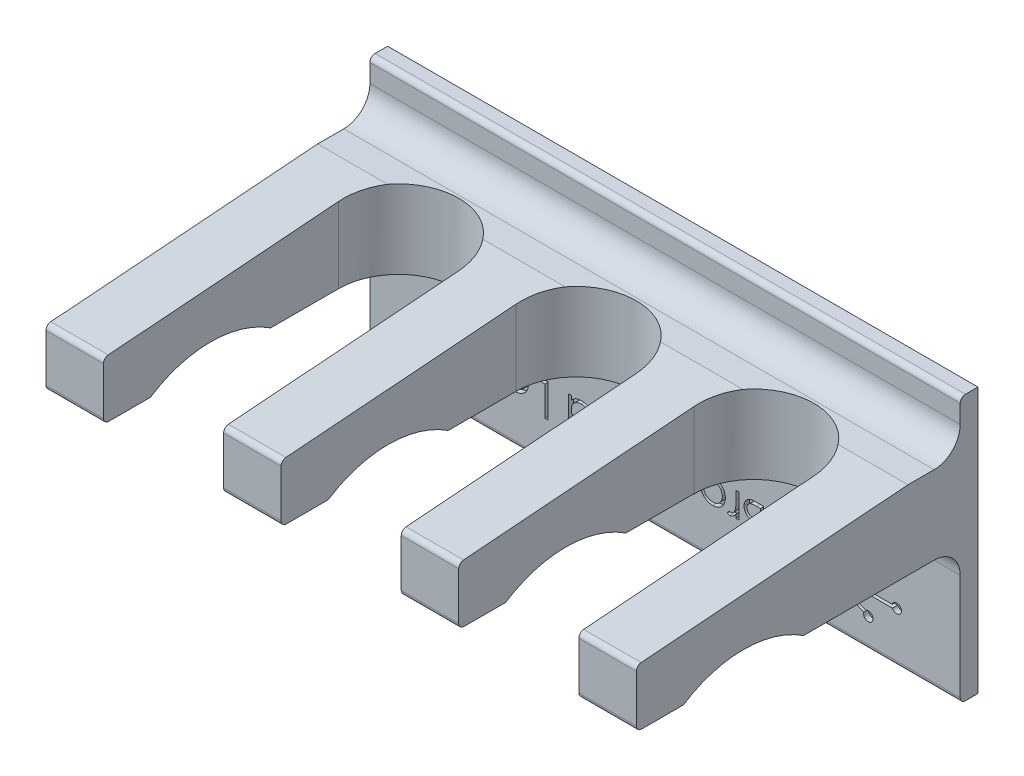
from build123d import *

# Parameters (mm, degrees)
SKETCH1_W                = 113
SKETCH1_H                = 3.4
BOSS_EXTRUDE1_DEPTH      = 30
BOSS_EXTRUDE1_DEPTH_BACK = 20.8
SKETCH2_W                = 113
SKETCH2_H                = 15
BOSS_EXTRUDE2_DEPTH      = 62
CUT_EXTRUDE1_DEPTH       = 1
CUT_EXTRUDE1_DEPTH_BACK  = 114
SKETCH5_W                = 23
SKETCH5_H                = 13
SKETCH5_H_2              = 32
CUT_EXTRUDE5_DEPTH       = 25.5
CUT_EXTRUDE5_DEPTH_BACK  = 27.3
FILLET1_R                = 5
FILLET2_R                = 1
FILLET3_R                = 1
CUT_EXTRUDE6_DEPTH       = 1
CUT_EXTRUDE7_DEPTH       = 1


with BuildPart() as part:
    # Sketch1 → Boss-Extrude1 (new body, two sides)
    with BuildSketch(Plane(origin=(0, 0, 0), x_dir=(1, 0, 0), z_dir=(0, 1, 0))) as boss_extrude1_sk:
        Rectangle(SKETCH1_W, SKETCH1_H)
    extrude(amount=BOSS_EXTRUDE1_DEPTH)
    extrude(boss_extrude1_sk.sketch, amount=-BOSS_EXTRUDE1_DEPTH_BACK)

    # Sketch2 → Boss-Extrude2 (add)
    with BuildSketch(Plane.XY.offset(1.7)):
        with Locations((0, 13)):
            Rectangle(SKETCH2_W, SKETCH2_H)
    extrude(amount=BOSS_EXTRUDE2_DEPTH)

    # Sketch4 → Cut-Extrude1 (cut, two sides)
    with BuildSketch(Plane.ZY.offset(56.5)) as cut_extrude1_sk:
        with BuildLine():
            Line((31.7, 5.5), (54.7, 5.5))
            ThreePointArc((54.7, 5.5), (43.2, 8.9278273), (31.7, 5.5))
        make_face()
        Polygon((63.7, 20.5), (11.7, 20.5), (63.7, 16.5), align=None)
    extrude(amount=CUT_EXTRUDE1_DEPTH, mode=Mode.SUBTRACT)
    extrude(cut_extrude1_sk.sketch, amount=-CUT_EXTRUDE1_DEPTH_BACK, mode=Mode.SUBTRACT)

    # Sketch5 → Cut-Extrude5 (cut, two sides)
    with BuildSketch(Plane(origin=(0, 5.5, 1.030668591), x_dir=(1, 0, 0), z_dir=(0, 1, 0))) as cut_extrude5_sk:
        with Locations((34, -24.169331409)):
            Rectangle(SKETCH5_W, SKETCH5_H)
        with Locations((34, -46.669331409)):
            Rectangle(SKETCH5_W, SKETCH5_H_2)
        with BuildLine():
            Line((22.5, -17.669331409), (45.5, -17.669331409))
            ThreePointArc((45.5, -17.669331409), (34, -6.169331409), (22.5, -17.669331409))
        make_face()
        with BuildLine():
            Line((-11.5, -17.669331409), (11.5, -17.669331409))
            ThreePointArc((11.5, -17.669331409), (0, -6.169331409), (-11.5, -17.669331409))
        make_face()
        with Locations((0, -24.169331409)):
            Rectangle(SKETCH5_W, SKETCH5_H)
        with Locations((0, -46.669331409)):
            Rectangle(SKETCH5_W, SKETCH5_H_2)
        with Locations((-34, -24.169331409)):
            Rectangle(SKETCH5_W, SKETCH5_H)
        with Locations((-34, -46.669331409)):
            Rectangle(SKETCH5_W, SKETCH5_H_2)
        with BuildLine():
            Line((-45.5, -17.669331409), (-22.5, -17.669331409))
            ThreePointArc((-22.5, -17.669331409), (-34, -6.169331409), (-45.5, -17.669331409))
        make_face()
    extrude(amount=CUT_EXTRUDE5_DEPTH, mode=Mode.SUBTRACT)
    extrude(cut_extrude5_sk.sketch, amount=-CUT_EXTRUDE5_DEPTH_BACK, mode=Mode.SUBTRACT)

    # Fillet1
    fillet1_edges = [part.edges().sort_by_distance(p)[0] for p in [
        (0, 20.5, 1.7),
        (0, 5.5, 1.7),
    ]]
    fillet(fillet1_edges, radius=FILLET1_R)

    # Fillet2
    fillet2_edges = [part.edges().sort_by_distance(p)[0] for p in [
        (0, -20.8, 1.7),
        (0, 30, 1.7),
    ]]
    fillet(fillet2_edges, radius=FILLET2_R)

    # Fillet3
    fillet3_edges = [part.edges().sort_by_distance(p)[0] for p in [
        (-51, 5.5, 63.7),
        (51, 5.5, 63.7),
        (-51, 16.5, 63.7),
        (51, 16.5, 63.7),
        (-17, 5.5, 63.7),
        (-17, 16.5, 63.7),
        (17, 5.5, 63.7),
        (17, 16.5, 63.7),
    ]]
    fillet(fillet3_edges, radius=FILLET3_R)

    # Sketch6 → Cut-Extrude6 (cut)
    with BuildSketch(Plane.XY.offset(1.7)):
        with BuildLine():
            ThreePointArc((30.34513405, -13.148436359), (32.587188023, -10.934389264), (30.34513405, -8.720342169))
            Line((30.34513405, -8.720342169), (30.34513405, -13.148436359))
        make_face()
        with BuildLine():
            ThreePointArc((32.387441567, -11.853447127), (32.24184238, -12.12185726), (32.060700113, -12.367683626))
            Line((32.060700113, -12.367683626), (38.039510272, -14.835483008))
            ThreePointArc((38.039510272, -14.835483008), (39.610179565, -15.655987061), (38.41974035, -14.343324346))
            Line((38.41974035, -14.343324346), (32.387441567, -11.853447127))
        make_face()
        with BuildLine():
            Line((43.46867274, -10.840081745), (32.585178752, -10.840081745))
            ThreePointArc((32.585178752, -10.840081745), (32.577432245, -11.142013304), (32.528668735, -11.440081745))
            Line((32.528668735, -11.440081745), (43.52283179, -11.440081745))
            ThreePointArc((43.52283179, -11.440081745), (45.236769861, -10.982928647), (43.46867274, -10.840081745))
        make_face()
        with BuildLine():
            Line((40.600693883, -5.29166271), (32.008087594, -9.441353251))
            ThreePointArc((32.008087594, -9.441353251), (32.197318076, -9.679591006), (32.352104444, -9.941519591))
            Line((32.352104444, -9.941519591), (40.937031121, -5.795537821))
            ThreePointArc((40.937031121, -5.795537821), (42.222305686, -4.573425208), (40.600693883, -5.29166271))
        make_face()
        with BuildLine():
            Line((34.263370153, -3.898677216), (31.204024561, -8.882044062))
            ThreePointArc((31.204024561, -8.882044062), (31.474546268, -9.013634185), (31.724734456, -9.180678568))
            Line((31.724734456, -9.180678568), (34.768542833, -4.222620286))
            ThreePointArc((34.768542833, -4.222620286), (35.459803154, -2.588768066), (34.263370153, -3.898677216))
        make_face()
    extrude(amount=-CUT_EXTRUDE6_DEPTH, mode=Mode.SUBTRACT)

    # Sketch8 → Cut-Extrude7 (cut)
    with BuildSketch(Plane.XY.offset(1.7)):
        with BuildLine():
            Line((18.858305169, -13.246753353), (17.61934283, -13.246753353))
            add(Edge.make_bspline(
                [(17.61934283, -13.246753353), (17.558693063, -13.246439511), (17.44113872, -13.245831208), (17.270210732, -13.236177878), (17.110057146, -13.223344689), (16.960960974, -13.201817705), (16.82195207, -13.179497061), (16.694441666, -13.146735701), (16.577361703, -13.110549584), (16.436772632, -13.054872333), (16.277255068, -12.968404859), (16.105803534, -12.84016538), (15.956767399, -12.6864166), (15.830042508, -12.511207737), (15.728343086, -12.318458134), (15.655698842, -12.11231486), (15.609029413, -11.896246028), (15.60429009, -11.748110867), (15.601894913, -11.673245741)],
                knots=[0, 0, 0, 0, 0.000181919, 0.000352604, 0.00051349, 0.000663703, 0.000804446, 0.000935564, 0.001058268, 0.001171886, 0.001388733, 0.0016004, 0.001811791, 0.002028575, 0.002247069, 0.002463125, 0.00268266, 0.002906975, 0.002906975, 0.002906975, 0.002906975], degree=3))
            add(Edge.make_bspline(
                [(15.601894913, -11.673245741), (15.603851328, -11.603110006), (15.607695867, -11.465286672), (15.645253907, -11.264379878), (15.701946858, -11.0725319), (15.783758229, -10.891591568), (15.888074602, -10.723148801), (16.014991144, -10.570076804), (16.165479379, -10.43538088), (16.278466777, -10.360420682), (16.335859256, -10.322344299)],
                knots=[0, 0, 0, 0, 0.000210198, 0.000413059, 0.000611047, 0.000809174, 0.001006844, 0.001203751, 0.001403723, 0.001610162, 0.001610162, 0.001610162, 0.001610162], degree=3))
            add(Edge.make_bspline(
                [(16.335859256, -10.322344299), (16.263717361, -10.294661646), (16.125692044, -10.241697875), (15.935505587, -10.147695874), (15.771591767, -10.046237996), (15.631838185, -9.936580585), (15.514734558, -9.815143016), (15.410413944, -9.68512343), (15.321880246, -9.541993685), (15.246341249, -9.388855335), (15.18650236, -9.226519343), (15.144965851, -9.056200176), (15.118623264, -8.879826934), (15.115178491, -8.759954482), (15.113433375, -8.699227311)],
                knots=[0, 0, 0, 0, 0.000231723, 0.000443344, 0.00063535, 0.000809177, 0.000974689, 0.001140371, 0.001308376, 0.001478472, 0.001651922, 0.001826233, 0.002003608, 0.002185726, 0.002185726, 0.002185726, 0.002185726], degree=3))
            add(Edge.make_bspline(
                [(15.113433375, -8.699227311), (15.115205822, -8.637238946), (15.118693163, -8.515275102), (15.144417254, -8.336103599), (15.187985563, -8.164885895), (15.247953218, -8.000482291), (15.326124074, -7.843855652), (15.420562593, -7.693775065), (15.533908733, -7.552464748), (15.661547636, -7.417874113), (15.803955929, -7.294796792), (15.960878726, -7.18902819), (16.128294259, -7.0976715), (16.308495084, -7.024225845), (16.500202552, -6.966731331), (16.703461575, -6.926979719), (16.918156734, -6.900087504), (17.065496564, -6.897883595), (17.141057573, -6.896753353)],
                knots=[0, 0, 0, 0, 0.00018593, 0.000365823, 0.000541677, 0.000715127, 0.000889772, 0.001065869, 0.001246054, 0.001432298, 0.001621733, 0.00180943, 0.001998968, 0.002192906, 0.002392113, 0.002598422, 0.002813633, 0.003040184, 0.003040184, 0.003040184, 0.003040184], degree=3))
            Line((17.141057573, -6.896753353), (18.858305169, -6.896753353))
            Line((18.858305169, -6.896753353), (18.858305169, -13.246753353))
        make_face()
        with BuildLine():
            Line((18.288433375, -12.595471302), (18.288433375, -10.560214891))
            Line((18.288433375, -10.560214891), (17.905550762, -10.560214891))
            add(Edge.make_bspline(
                [(17.905550762, -10.560214891), (17.84958173, -10.560934428), (17.741438152, -10.562324719), (17.584413011, -10.566432769), (17.439021013, -10.577431758), (17.304761194, -10.589065024), (17.182533319, -10.606977798), (17.07192854, -10.628898233), (16.971952184, -10.651877703), (16.856713321, -10.69107077), (16.726012691, -10.748387691), (16.587657647, -10.83951708), (16.463131889, -10.945025211), (16.360405325, -11.070174341), (16.274881733, -11.205324084), (16.217302019, -11.351482255), (16.177155301, -11.503612204), (16.173581305, -11.608528885), (16.171766708, -11.661797424)],
                knots=[0, 0, 0, 0, 0.000167928, 0.000324471, 0.000471109, 0.000605277, 0.000728684, 0.000841444, 0.000943564, 0.001036082, 0.001206311, 0.001370024, 0.001531452, 0.001693994, 0.001853912, 0.002009105, 0.002163672, 0.002323088, 0.002323088, 0.002323088, 0.002323088], degree=3))
            add(Edge.make_bspline(
                [(16.171766708, -11.661797424), (16.172651716, -11.697062359), (16.174387757, -11.76623838), (16.190754098, -11.867023871), (16.213339453, -11.962931827), (16.250588329, -12.051376742), (16.294718621, -12.135464276), (16.351283113, -12.212538267), (16.416507176, -12.284686656), (16.49255026, -12.349975575), (16.579101514, -12.409025633), (16.678902679, -12.458181987), (16.789240404, -12.501866639), (16.912415576, -12.534980629), (17.045974657, -12.563728844), (17.191955283, -12.581857308), (17.349477678, -12.59350332), (17.458618938, -12.594800676), (17.515035939, -12.595471302)],
                knots=[0, 0, 0, 0, 0.000105701, 0.000207345, 0.000305761, 0.000400483, 0.00049439, 0.000590064, 0.000686411, 0.000785614, 0.000890045, 0.000999838, 0.001118656, 0.00124551, 0.001381974, 0.001528235, 0.001686383, 0.001855606, 0.001855606, 0.001855606, 0.001855606], degree=3))
            Line((17.515035939, -12.595471302), (18.288433375, -12.595471302))
        make_face(mode=Mode.SUBTRACT)
        with BuildLine():
            Line((18.288433375, -9.90893284), (18.288433375, -7.548035404))
            Line((18.288433375, -7.548035404), (17.476874881, -7.548035404))
            add(Edge.make_bspline(
                [(17.476874881, -7.548035404), (17.418789208, -7.548798579), (17.306836732, -7.550269498), (17.145073619, -7.553759786), (16.995940409, -7.566708741), (16.858195413, -7.5791234), (16.732475964, -7.599405324), (16.617559224, -7.619045225), (16.516069946, -7.647946309), (16.397321628, -7.687714713), (16.264502829, -7.751269893), (16.119458434, -7.84473323), (15.991704493, -7.958578461), (15.883314226, -8.089664782), (15.793192471, -8.230724634), (15.730846014, -8.382035647), (15.69044906, -8.538543787), (15.68569126, -8.645558312), (15.683305169, -8.699227311)],
                knots=[0, 0, 0, 0, 0.000174287, 0.000335916, 0.000485184, 0.000623274, 0.000750643, 0.000867151, 0.000972691, 0.001066822, 0.001242648, 0.001412707, 0.001582993, 0.001753678, 0.001921683, 0.002083036, 0.002242848, 0.002403628, 0.002403628, 0.002403628, 0.002403628], degree=3))
            add(Edge.make_bspline(
                [(15.683305169, -8.699227311), (15.683792244, -8.732784547), (15.684758536, -8.799357738), (15.699947684, -8.89710307), (15.721026338, -8.992255374), (15.752090352, -9.083522167), (15.789669363, -9.172475047), (15.839245652, -9.25621965), (15.89516734, -9.338320853), (15.981781576, -9.443337381), (16.109480678, -9.56287359), (16.291009458, -9.678444576), (16.496259942, -9.7731586), (16.645476537, -9.81319895), (16.722557974, -9.83388276)],
                knots=[0, 0, 0, 0, 0.000100563, 0.000199504, 0.000296087, 0.000392628, 0.000488335, 0.00058521, 0.000684004, 0.000786124, 0.000993126, 0.001205526, 0.001429234, 0.001668282, 0.001668282, 0.001668282, 0.001668282], degree=3))
            add(Edge.make_bspline(
                [(16.722557974, -9.83388276), (16.75345359, -9.840151691), (16.82044166, -9.853744026), (16.929675968, -9.868082757), (17.054800637, -9.880945065), (17.195280863, -9.89020952), (17.351675354, -9.900154751), (17.523933866, -9.903884819), (17.712178179, -9.908437565), (17.842793071, -9.908763525), (17.910638903, -9.90893284)],
                knots=[0, 0, 0, 0, 9.4551e-05, 0.000205006, 0.000330312, 0.000471875, 0.000627318, 0.00080039, 0.00098869, 0.001192219, 0.001192219, 0.001192219, 0.001192219], degree=3))
            Line((17.910638903, -9.90893284), (18.288433375, -9.90893284))
        make_face(mode=Mode.SUBTRACT)
        with BuildLine():
            Line((14.136510298, -11.537137968), (13.566638503, -11.537137968))
            Line((13.566638503, -11.537137968), (13.566638503, -10.854055036))
            add(Edge.make_bspline(
                [(13.566638503, -10.854055036), (13.524599432, -10.917691443), (13.444200037, -11.039395577), (13.309859538, -11.200037923), (13.173763818, -11.335161147), (13.031283027, -11.440260096), (12.886040493, -11.5203491), (12.738465888, -11.577108882), (12.587494207, -11.611705885), (12.485584455, -11.61626439), (12.434527125, -11.618548225)],
                knots=[0, 0, 0, 0, 0.000228641, 0.000437274, 0.00062708, 0.000802626, 0.00096658, 0.001123206, 0.001275665, 0.001428738, 0.001428738, 0.001428738, 0.001428738], degree=3))
            add(Edge.make_bspline(
                [(12.434527125, -11.618548225), (12.394915102, -11.61643659), (12.313823363, -11.612113759), (12.19069484, -11.580221521), (12.063311639, -11.531235857), (11.981108715, -11.484043536), (11.938433375, -11.459543818)],
                knots=[0, 0, 0, 0, 0.000118736, 0.000243071, 0.000379606, 0.000527014, 0.000527014, 0.000527014, 0.000527014], degree=3))
            Line((11.938433375, -11.459543818), (12.251354048, -10.965994138))
            add(Edge.make_bspline(
                [(12.251354048, -10.965994138), (12.278766129, -10.978222907), (12.330799507, -11.00143545), (12.406917077, -11.028907383), (12.477096073, -11.045083402), (12.521806529, -11.047533989), (12.542650121, -11.04867643)],
                knots=[0, 0, 0, 0, 9.0027e-05, 0.000170889, 0.000242497, 0.000305034, 0.000305034, 0.000305034, 0.000305034], degree=3))
            add(Edge.make_bspline(
                [(12.542650121, -11.04867643), (12.588853792, -11.045764564), (12.682254125, -11.039878252), (12.81872519, -10.989585764), (12.952923521, -10.913999352), (13.057145337, -10.824838983), (13.138743883, -10.740825606), (13.197464806, -10.666894282), (13.250202768, -10.583283681), (13.301349304, -10.493160804), (13.348871282, -10.394282645), (13.391338309, -10.286482479), (13.431053409, -10.170652051), (13.453419081, -10.090112389), (13.464875682, -10.048856718)],
                knots=[0, 0, 0, 0, 0.000138225, 0.000279421, 0.000431518, 0.000598621, 0.000688585, 0.00078275, 0.000881191, 0.000984852, 0.00109352, 0.001209972, 0.00133226, 0.001460685, 0.001460685, 0.001460685, 0.001460685], degree=3))
            add(Edge.make_bspline(
                [(13.464875682, -10.048856718), (13.473476434, -10.012070169), (13.492621977, -9.93018216), (13.510740147, -9.79342602), (13.529362671, -9.631957083), (13.542079981, -9.445587768), (13.554093175, -9.233601669), (13.560729759, -8.996913295), (13.56642735, -8.734872102), (13.566565873, -8.552099399), (13.566638503, -8.456268577)],
                knots=[0, 0, 0, 0, 0.000113275, 0.000252155, 0.000413417, 0.000600929, 0.000812397, 0.00105039, 0.001311207, 0.00159869, 0.00159869, 0.00159869, 0.00159869], degree=3))
            Line((13.566638503, -8.456268577), (13.566638503, -6.896753353))
            Line((13.566638503, -6.896753353), (14.136510298, -6.896753353))
            Line((14.136510298, -6.896753353), (14.136510298, -11.537137968))
        make_face()
        with BuildLine():
            add(Edge.make_bspline(
                [(9.127235458, -11.618548225), (9.040163416, -11.616699663), (8.86943642, -11.613075086), (8.619444149, -11.574145174), (8.381058386, -11.515110448), (8.15325653, -11.432011392), (7.937922961, -11.322982186), (7.733135104, -11.19113343), (7.539303262, -11.035573097), (7.423152039, -10.915170464), (7.364194592, -10.854055036)],
                knots=[0, 0, 0, 0, 0.000261018, 0.000511793, 0.000757062, 0.000996914, 0.001237547, 0.001479599, 0.001726534, 0.001981084, 0.001981084, 0.001981084, 0.001981084], degree=3))
            add(Edge.make_bspline(
                [(7.364194592, -10.854055036), (7.313427333, -10.795609661), (7.2128753, -10.679849992), (7.083941782, -10.492151951), (6.97286838, -10.297769197), (6.883854151, -10.094120476), (6.813668465, -9.882983573), (6.763837844, -9.663632781), (6.734197977, -9.436552523), (6.730201165, -9.282331274), (6.728176964, -9.204225308)],
                knots=[0, 0, 0, 0, 0.000232086, 0.000459681, 0.000681833, 0.000902819, 0.001125265, 0.001348369, 0.001576673, 0.001810949, 0.001810949, 0.001810949, 0.001810949], degree=3))
            add(Edge.make_bspline(
                [(6.728176964, -9.204225308), (6.729957391, -9.125666632), (6.733475596, -8.970431024), (6.766756158, -8.741795891), (6.818519696, -8.520099563), (6.892600328, -8.306270243), (6.987592856, -8.099654165), (7.103508976, -7.901154332), (7.241161159, -7.710376975), (7.397199339, -7.528950274), (7.569641808, -7.361715012), (7.756755802, -7.216046893), (7.954999861, -7.090722353), (8.167080212, -6.991179822), (8.389977959, -6.910941609), (8.625110872, -6.855612197), (8.872269192, -6.821859754), (9.041051205, -6.817545871), (9.127235458, -6.815343097)],
                knots=[0, 0, 0, 0, 0.000235546, 0.000465451, 0.000691608, 0.000917687, 0.001143082, 0.001372814, 0.001606155, 0.001847882, 0.00208988, 0.002325505, 0.002558096, 0.002791947, 0.003026912, 0.003267566, 0.003515286, 0.003773763, 0.003773763, 0.003773763, 0.003773763], degree=3))
            add(Edge.make_bspline(
                [(9.127235458, -6.815343097), (9.213837817, -6.817564097), (9.383452914, -6.821914039), (9.631541889, -6.855361127), (9.867664784, -6.911532781), (10.091616889, -6.99018649), (10.303696381, -7.091539964), (10.502672459, -7.215559267), (10.689874711, -7.361788775), (10.862371244, -7.528930287), (11.018394928, -7.710382125), (11.156050852, -7.901152995), (11.271966, -8.099654513), (11.366958782, -8.30627015), (11.441039346, -8.520099588), (11.492802903, -8.741795884), (11.52608346, -8.970431026), (11.529601666, -9.125666633), (11.531382092, -9.204225308)],
                knots=[0, 0, 0, 0, 0.000259748, 0.000508729, 0.000749382, 0.000986746, 0.001219448, 0.001453119, 0.001688744, 0.001930742, 0.002172469, 0.00240581, 0.002635542, 0.002860936, 0.003087015, 0.003313173, 0.003543077, 0.003778624, 0.003778624, 0.003778624, 0.003778624], degree=3))
            add(Edge.make_bspline(
                [(11.531382092, -9.204225308), (11.529348928, -9.281908489), (11.525323613, -9.435707836), (11.495643296, -9.66233607), (11.446354871, -9.881015521), (11.375196211, -10.090999447), (11.28634722, -10.294158703), (11.176391723, -10.489254169), (11.046210989, -10.676132048), (10.946049599, -10.791738207), (10.895364464, -10.85023893)],
                knots=[0, 0, 0, 0, 0.000233005, 0.000461309, 0.000684413, 0.000904446, 0.001125432, 0.001348692, 0.001575243, 0.001807329, 0.001807329, 0.001807329, 0.001807329], degree=3))
            add(Edge.make_bspline(
                [(10.895364464, -10.85023893), (10.836491024, -10.911874072), (10.720706044, -11.033090423), (10.525979446, -11.188343828), (10.322072516, -11.321970222), (10.105349972, -11.430944559), (9.876914695, -11.514959672), (9.636757202, -11.574420707), (9.385855009, -11.612902888), (9.214301099, -11.616647692), (9.127235458, -11.618548225)],
                knots=[0, 0, 0, 0, 0.000255448, 0.000502383, 0.000745126, 0.000985759, 0.001228438, 0.001473706, 0.001726998, 0.001988016, 0.001988016, 0.001988016, 0.001988016], degree=3))
        make_face()
        with BuildLine():
            add(Edge.make_bspline(
                [(9.129779528, -11.04867643), (9.191351983, -11.04692629), (9.312907409, -11.043471191), (9.491832508, -11.017194614), (9.664077391, -10.97555624), (9.829990784, -10.916421768), (9.988931146, -10.839972114), (10.141072776, -10.746602008), (10.286009143, -10.63581516), (10.422618227, -10.509809674), (10.549488663, -10.372957502), (10.659024104, -10.225756595), (10.752862288, -10.072297234), (10.829535755, -9.911712052), (10.888359189, -9.743559867), (10.930037446, -9.568802762), (10.956363891, -9.386920613), (10.959776244, -9.263253207), (10.961510298, -9.200409202)],
                knots=[0, 0, 0, 0, 0.00018466, 0.000364553, 0.000541334, 0.000715547, 0.00089192, 0.001069504, 0.001250138, 0.0014383, 0.001626463, 0.001809127, 0.001987797, 0.002165318, 0.002341929, 0.002521182, 0.002703594, 0.002892066, 0.002892066, 0.002892066, 0.002892066], degree=3))
            add(Edge.make_bspline(
                [(10.961510298, -9.200409202), (10.958602753, -9.119212651), (10.952831821, -8.958052679), (10.905664772, -8.720776689), (10.827318106, -8.492556832), (10.719283302, -8.276140936), (10.58623519, -8.075557991), (10.43066271, -7.895192861), (10.250415018, -7.742001148), (10.051629895, -7.613164338), (9.837124377, -7.511705472), (9.610494743, -7.438945973), (9.373804522, -7.392284686), (9.211833083, -7.387592114), (9.129779528, -7.385214891)],
                knots=[0, 0, 0, 0, 0.000243438, 0.000483178, 0.000722527, 0.000965436, 0.001206751, 0.001442966, 0.001677518, 0.001913915, 0.002151758, 0.002387085, 0.002626586, 0.002872487, 0.002872487, 0.002872487, 0.002872487], degree=3))
            add(Edge.make_bspline(
                [(9.129779528, -7.385214891), (9.047721254, -7.387578344), (8.885740498, -7.392243733), (8.648720954, -7.439182375), (8.4214702, -7.511389088), (8.206741651, -7.61327893), (8.007866001, -7.741514179), (7.828905402, -7.89606558), (7.671993152, -8.075083844), (7.538813298, -8.275874977), (7.432519234, -8.492893277), (7.353804126, -8.720734638), (7.306750197, -8.958063389), (7.300963996, -9.119216239), (7.298048759, -9.200409202)],
                knots=[0, 0, 0, 0, 0.000245901, 0.000485402, 0.000721939, 0.000959783, 0.001196179, 0.001429767, 0.00166682, 0.001908134, 0.00215048, 0.002389829, 0.002629569, 0.002873007, 0.002873007, 0.002873007, 0.002873007], degree=3))
            add(Edge.make_bspline(
                [(7.298048759, -9.200409202), (7.299769822, -9.263258258), (7.303156611, -9.386935605), (7.329668993, -9.56874545), (7.370693052, -9.74390791), (7.432052637, -9.91103388), (7.506054816, -10.073078976), (7.602167994, -10.225297007), (7.711193517, -10.373050878), (7.838296524, -10.509727232), (7.974890274, -10.636275537), (8.120915466, -10.746198437), (8.273127758, -10.840025433), (8.432118348, -10.916431184), (8.597656288, -10.975328629), (8.769378226, -11.017375997), (8.94751096, -11.043375384), (9.068634752, -11.046898113), (9.129779528, -11.04867643)],
                knots=[0, 0, 0, 0, 0.000188472, 0.000370883, 0.000550137, 0.000727174, 0.000904151, 0.001083486, 0.00126615, 0.001454312, 0.001642475, 0.001824122, 0.002001707, 0.00217808, 0.002352293, 0.002527838, 0.002707731, 0.002891121, 0.002891121, 0.002891121, 0.002891121], degree=3))
        make_face(mode=Mode.SUBTRACT)
        with BuildLine():
            Line((5.669843631, -11.537137968), (5.099971836, -11.537137968))
            Line((5.099971836, -11.537137968), (5.099971836, -9.384854315))
            add(Edge.make_bspline(
                [(5.099971836, -9.384854315), (5.09971438, -9.321675898), (5.099221879, -9.200818547), (5.095881886, -9.026909851), (5.088025859, -8.868310958), (5.078203634, -8.72493025), (5.06557233, -8.596791982), (5.050543948, -8.48434372), (5.033746526, -8.386310272), (5.017304173, -8.327267327), (5.009657333, -8.299808241)],
                knots=[0, 0, 0, 0, 0.000189538, 0.000362576, 0.000521764, 0.000665864, 0.000793702, 0.000907937, 0.001006238, 0.001091702, 0.001091702, 0.001091702, 0.001091702], degree=3))
            add(Edge.make_bspline(
                [(5.009657333, -8.299808241), (4.997390041, -8.265295414), (4.973110492, -8.196987273), (4.929072627, -8.098308681), (4.874588293, -8.006918724), (4.814987331, -7.919262039), (4.746165921, -7.838051366), (4.669130353, -7.762756291), (4.585247994, -7.692498471), (4.462376946, -7.607761922), (4.294410698, -7.518087152), (4.074380192, -7.439632943), (3.835370696, -7.393435067), (3.669984757, -7.388005593), (3.584977846, -7.385214891)],
                knots=[0, 0, 0, 0, 0.000109875, 0.000217465, 0.000323495, 0.000428644, 0.000535161, 0.000642201, 0.000751486, 0.00086299, 0.001089487, 0.001320431, 0.00156142, 0.001816285, 0.001816285, 0.001816285, 0.001816285], degree=3))
            add(Edge.make_bspline(
                [(3.584977846, -7.385214891), (3.499960162, -7.38799517), (3.335883486, -7.393360863), (3.099371289, -7.438935444), (2.882772574, -7.513286615), (2.688616327, -7.618527919), (2.518121382, -7.746830737), (2.376058376, -7.897443514), (2.25884144, -8.065533135), (2.207661614, -8.190944706), (2.181922958, -8.254014972)],
                knots=[0, 0, 0, 0, 0.000254865, 0.000491866, 0.000719564, 0.000939255, 0.001151688, 0.001356837, 0.001558293, 0.001762105, 0.001762105, 0.001762105, 0.001762105], degree=3))
            add(Edge.make_bspline(
                [(2.181922958, -8.254014972), (2.174307797, -8.279353289), (2.157472537, -8.335370122), (2.139513799, -8.430413027), (2.122666683, -8.543644905), (2.111434878, -8.67625489), (2.098615937, -8.827073579), (2.094189524, -8.996880916), (2.087868376, -9.184675997), (2.08781844, -9.3161565), (2.087792349, -9.384854315)],
                knots=[0, 0, 0, 0, 7.9326e-05, 0.000175371, 0.000289784, 0.000422686, 0.00057449, 0.00074379, 0.00093212, 0.001138194, 0.001138194, 0.001138194, 0.001138194], degree=3))
            Line((2.087792349, -9.384854315), (2.087792349, -11.537137968))
            Line((2.087792349, -11.537137968), (1.517920554, -11.537137968))
            Line((1.517920554, -11.537137968), (1.517920554, -9.278003353))
            add(Edge.make_bspline(
                [(1.517920554, -9.278003353), (1.518724792, -9.201246483), (1.520285124, -9.052327655), (1.530237877, -8.835906394), (1.547552594, -8.633827526), (1.573155043, -8.446709656), (1.604214345, -8.274508031), (1.643489115, -8.117168472), (1.690634199, -7.974472153), (1.743832698, -7.844337037), (1.806524436, -7.726233518), (1.873658301, -7.614767108), (1.949143764, -7.510305279), (2.031471524, -7.411892322), (2.12302444, -7.321916404), (2.219021551, -7.235764247), (2.324150626, -7.158750857), (2.434868793, -7.086773761), (2.553967322, -7.022899067), (2.680421836, -6.967630076), (2.814098565, -6.91961066), (2.95520629, -6.882503715), (3.103662267, -6.851197936), (3.259276937, -6.830361303), (3.422346446, -6.817057328), (3.533220703, -6.815924102), (3.590065987, -6.815343097)],
                knots=[0, 0, 0, 0, 0.00023027, 0.000446755, 0.000649791, 0.000838503, 0.001013148, 0.001174501, 0.001324542, 0.001463683, 0.001595681, 0.001725266, 0.001853767, 0.001981946, 0.00210967, 0.002238548, 0.002368551, 0.002500162, 0.002634475, 0.002773447, 0.002913862, 0.003060124, 0.003210805, 0.003368752, 0.003530801, 0.003701296, 0.003701296, 0.003701296, 0.003701296], degree=3))
            add(Edge.make_bspline(
                [(3.590065987, -6.815343097), (3.646484248, -6.81595856), (3.757351384, -6.817168004), (3.920036392, -6.830137484), (4.075986969, -6.851517104), (4.224559817, -6.882252774), (4.36635377, -6.919909752), (4.500680431, -6.967292467), (4.627709425, -7.02321532), (4.747714067, -7.086833445), (4.860296217, -7.158488866), (4.965202833, -7.237353676), (5.064304128, -7.321370206), (5.154849182, -7.413403816), (5.237502103, -7.512765462), (5.312621218, -7.619008643), (5.381491361, -7.730932588), (5.44381553, -7.850791902), (5.497358749, -7.982457726), (5.544630271, -8.128139764), (5.5832939, -8.289434281), (5.614758079, -8.466203652), (5.640069983, -8.657601794), (5.657643411, -8.86473592), (5.667469276, -9.087101476), (5.669035116, -9.240680562), (5.669843631, -9.319980516)],
                knots=[0, 0, 0, 0, 0.000169224, 0.00033254, 0.000489228, 0.000641155, 0.000787417, 0.000929031, 0.001068003, 0.001203437, 0.00133612, 0.001467903, 0.001596906, 0.001725533, 0.001854687, 0.001984222, 0.002115557, 0.002248683, 0.002389, 0.002541458, 0.00270775, 0.002886148, 0.003079903, 0.003286741, 0.003509579, 0.003747481, 0.003747481, 0.003747481, 0.003747481], degree=3))
            Line((5.669843631, -9.319980516), (5.669843631, -11.537137968))
        make_face()
        with BuildLine():
            Line((0.215356451, -13.409573866), (-0.354515343, -13.409573866))
            Line((-0.354515343, -13.409573866), (-0.354515343, -10.660705677))
            add(Edge.make_bspline(
                [(-0.354515343, -10.660705677), (-0.415785565, -10.737060583), (-0.534892534, -10.885491601), (-0.734002901, -11.081251426), (-0.941477361, -11.247992243), (-1.159076615, -11.384152106), (-1.385875859, -11.489779087), (-1.622432395, -11.563676329), (-1.868143139, -11.609757007), (-2.035520975, -11.615597108), (-2.120100279, -11.618548225)],
                knots=[0, 0, 0, 0, 0.000293488, 0.000570528, 0.000835738, 0.001090577, 0.001338715, 0.001584123, 0.001832378, 0.002085973, 0.002085973, 0.002085973, 0.002085973], degree=3))
            add(Edge.make_bspline(
                [(-2.120100279, -11.618548225), (-2.206012552, -11.615560804), (-2.374247882, -11.60971077), (-2.618316128, -11.558164558), (-2.847863599, -11.476591787), (-3.059823994, -11.361947277), (-3.250924371, -11.219601611), (-3.416673041, -11.052654664), (-3.555717815, -10.863305282), (-3.648749072, -10.686809554), (-3.709721933, -10.529853803), (-3.748264467, -10.395155753), (-3.780960824, -10.245078174), (-3.809443285, -10.079678195), (-3.828427622, -9.898168007), (-3.843675877, -9.701364616), (-3.854518909, -9.489279874), (-3.8549391, -9.342467418), (-3.855156369, -9.266555036)],
                knots=[0, 0, 0, 0, 0.000257483, 0.000504208, 0.000744821, 0.000986136, 0.001224262, 0.001457225, 0.001689255, 0.00192653, 0.002053383, 0.002193867, 0.002346326, 0.002514041, 0.002697078, 0.002893565, 0.003106238, 0.003333947, 0.003333947, 0.003333947, 0.003333947], degree=3))
            Line((-3.855156369, -9.266555036), (-3.855156369, -6.896753353))
            Line((-3.855156369, -6.896753353), (-3.285284574, -6.896753353))
            Line((-3.285284574, -6.896753353), (-3.285284574, -9.079565853))
            add(Edge.make_bspline(
                [(-3.285284574, -9.079565853), (-3.28494069, -9.142744206), (-3.284282899, -9.263593643), (-3.282081774, -9.436613958), (-3.277279926, -9.593122873), (-3.269233497, -9.733445277), (-3.261136908, -9.857391003), (-3.249658057, -9.965162503), (-3.23640236, -10.056083692), (-3.224483947, -10.110810895), (-3.219138741, -10.135355116)],
                knots=[0, 0, 0, 0, 0.000189538, 0.000362553, 0.000519096, 0.000659228, 0.000784205, 0.000891668, 0.000984317, 0.001059657, 0.001059657, 0.001059657, 0.001059657], degree=3))
            add(Edge.make_bspline(
                [(-3.219138741, -10.135355116), (-3.198508123, -10.207424719), (-3.158950662, -10.345612071), (-3.06516987, -10.532984947), (-2.950763993, -10.694188886), (-2.808959133, -10.824645209), (-2.644466103, -10.927436792), (-2.455723256, -10.997468753), (-2.245142385, -11.042128898), (-2.097026698, -11.046428901), (-2.019609494, -11.04867643)],
                knots=[0, 0, 0, 0, 0.00022447, 0.000430402, 0.000625302, 0.000814327, 0.00100458, 0.00120349, 0.001415294, 0.001647227, 0.001647227, 0.001647227, 0.001647227], degree=3))
            add(Edge.make_bspline(
                [(-2.019609494, -11.04867643), (-1.973762458, -11.047825571), (-1.883032359, -11.046141744), (-1.748564925, -11.028808479), (-1.617720179, -11.001432923), (-1.490849307, -10.960996789), (-1.367693508, -10.911834096), (-1.247752167, -10.851501637), (-1.132666756, -10.778553201), (-1.020951855, -10.696450459), (-0.916956267, -10.605623124), (-0.82020699, -10.509740151), (-0.733958506, -10.407642202), (-0.65581987, -10.300961751), (-0.588367813, -10.188236989), (-0.529488656, -10.070554566), (-0.479531034, -9.94775982), (-0.454706721, -9.862533637), (-0.442285776, -9.819890372)],
                knots=[0, 0, 0, 0, 0.000137474, 0.000272057, 0.000406032, 0.000537993, 0.00067098, 0.000803529, 0.000940117, 0.001079282, 0.001219049, 0.001353969, 0.001487527, 0.00161958, 0.001750253, 0.001881093, 0.00201408, 0.002147256, 0.002147256, 0.002147256, 0.002147256], degree=3))
            add(Edge.make_bspline(
                [(-0.442285776, -9.819890372), (-0.43513853, -9.789009504), (-0.4195638, -9.721716292), (-0.402664031, -9.61072859), (-0.387536885, -9.4817576), (-0.374748802, -9.33499894), (-0.366905488, -9.169914829), (-0.358454109, -8.987631803), (-0.355308112, -8.787008051), (-0.354787497, -8.647497631), (-0.354515343, -8.574567856)],
                knots=[0, 0, 0, 0, 9.5063e-05, 0.000207154, 0.000336533, 0.000484636, 0.00064897, 0.000832302, 0.001032048, 0.001250842, 0.001250842, 0.001250842, 0.001250842], degree=3))
            Line((-0.354515343, -8.574567856), (-0.354515343, -6.896753353))
            Line((-0.354515343, -6.896753353), (0.215356451, -6.896753353))
            Line((0.215356451, -6.896753353), (0.215356451, -13.409573866))
        make_face()
        with BuildLine():
            Line((-9.879515343, -11.537137968), (-9.879515343, -6.896753353))
            Line((-9.879515343, -6.896753353), (-9.309643549, -6.896753353))
            Line((-9.309643549, -6.896753353), (-9.309643549, -7.6994076))
            add(Edge.make_bspline(
                [(-9.309643549, -7.6994076), (-9.245296685, -7.626864497), (-9.11953623, -7.485085192), (-8.911504615, -7.298719672), (-8.689169452, -7.146561399), (-8.456318638, -7.023054231), (-8.211149828, -6.929952191), (-7.955102885, -6.864362957), (-7.688378149, -6.821696228), (-7.506486334, -6.817479806), (-7.414311016, -6.815343097)],
                knots=[0, 0, 0, 0, 0.000290762, 0.00056827, 0.000835367, 0.00109711, 0.001357209, 0.001620075, 0.001889028, 0.002165353, 0.002165353, 0.002165353, 0.002165353], degree=3))
            add(Edge.make_bspline(
                [(-7.414311016, -6.815343097), (-7.33236322, -6.817567717), (-7.170758538, -6.821954767), (-6.933037557, -6.856000256), (-6.704258367, -6.910646208), (-6.484275161, -6.986738548), (-6.274578505, -7.087151607), (-6.073986816, -7.208665279), (-5.882031948, -7.351951362), (-5.70236448, -7.516395744), (-5.536706622, -7.69481682), (-5.391772728, -7.885673217), (-5.268936535, -8.086343527), (-5.167987183, -8.296771352), (-5.089867281, -8.516802867), (-5.035516968, -8.746287127), (-5.001508167, -8.984842283), (-4.997123339, -9.147293253), (-4.994899959, -9.229666013)],
                knots=[0, 0, 0, 0, 0.00024577, 0.000484669, 0.00071884, 0.00095056, 0.001181567, 0.001414992, 0.001653117, 0.001898949, 0.002144702, 0.002382576, 0.002616662, 0.002849365, 0.003081507, 0.003315679, 0.003555837, 0.003802878, 0.003802878, 0.003802878, 0.003802878], degree=3))
            add(Edge.make_bspline(
                [(-4.994899959, -9.229666013), (-4.997172653, -9.310336219), (-5.001665647, -9.469816865), (-5.035153062, -9.704360391), (-5.091422636, -9.930290437), (-5.170540314, -10.146770075), (-5.271543347, -10.354671139), (-5.396492046, -10.552367008), (-5.541373713, -10.742881873), (-5.708802034, -10.920106259), (-5.890082083, -11.083216483), (-6.08311092, -11.22685078), (-6.285481668, -11.348052901), (-6.49760011, -11.446578443), (-6.717964259, -11.524872836), (-6.948248103, -11.579451566), (-7.187404405, -11.611535123), (-7.34976402, -11.616188062), (-7.43211951, -11.618548225)],
                knots=[0, 0, 0, 0, 0.000241958, 0.000478337, 0.000709106, 0.000939284, 0.001168551, 0.001401142, 0.001639787, 0.001885474, 0.002131398, 0.002370544, 0.002606149, 0.002837764, 0.003071106, 0.003306515, 0.003546502, 0.003793542, 0.003793542, 0.003793542, 0.003793542], degree=3))
            add(Edge.make_bspline(
                [(-7.43211951, -11.618548225), (-7.526826858, -11.615949527), (-7.712543499, -11.610853603), (-7.984570984, -11.568083393), (-8.24203059, -11.496495163), (-8.487152319, -11.398784607), (-8.716491417, -11.267203259), (-8.932252615, -11.104392954), (-9.131875827, -10.906406638), (-9.249362594, -10.755792404), (-9.309643549, -10.67851417)],
                knots=[0, 0, 0, 0, 0.000284009, 0.000556928, 0.00082357, 0.00108435, 0.001346417, 0.001614309, 0.001893149, 0.002186978, 0.002186978, 0.002186978, 0.002186978], degree=3))
            Line((-9.309643549, -10.67851417), (-9.309643549, -11.537137968))
            Line((-9.309643549, -11.537137968), (-9.879515343, -11.537137968))
        make_face()
        with BuildLine():
            add(Edge.make_bspline(
                [(-7.439751722, -11.04867643), (-7.356451737, -11.04571004), (-7.192030816, -11.039854857), (-6.950625784, -10.994219165), (-6.719737572, -10.918092437), (-6.499741648, -10.814580303), (-6.296711701, -10.681984454), (-6.112249553, -10.525643666), (-5.951355657, -10.343642466), (-5.815315341, -10.14016236), (-5.702376666, -9.923329589), (-5.624440209, -9.695011249), (-5.572674461, -9.461378326), (-5.567412848, -9.302869962), (-5.564771754, -9.223305837)],
                knots=[0, 0, 0, 0, 0.000249786, 0.000493037, 0.00073399, 0.000977521, 0.001220263, 0.001459368, 0.001700854, 0.001946406, 0.002192169, 0.002431934, 0.002668436, 0.002906796, 0.002906796, 0.002906796, 0.002906796], degree=3))
            add(Edge.make_bspline(
                [(-5.564771754, -9.223305837), (-5.56820022, -9.144236642), (-5.575043715, -8.986408176), (-5.622849889, -8.752417219), (-5.706763581, -8.525588478), (-5.81723177, -8.305960629), (-5.955413536, -8.100962782), (-6.115989874, -7.915601027), (-6.30138802, -7.756850252), (-6.50620577, -7.623879628), (-6.724729946, -7.516915446), (-6.954615739, -7.441473269), (-7.191856311, -7.393839739), (-7.353455577, -7.388099511), (-7.434663581, -7.385214891)],
                knots=[0, 0, 0, 0, 0.000237176, 0.000473422, 0.000712838, 0.000960869, 0.001209242, 0.001452636, 0.001694363, 0.001938865, 0.002183497, 0.002422033, 0.002663022, 0.00290646, 0.00290646, 0.00290646, 0.00290646], degree=3))
            add(Edge.make_bspline(
                [(-7.434663581, -7.385214891), (-7.517115209, -7.388216037), (-7.68068625, -7.394169837), (-7.922925993, -7.440120255), (-8.157571889, -7.517192241), (-8.382713013, -7.622141522), (-8.592094716, -7.752253102), (-8.779143488, -7.905252684), (-8.940735637, -8.080465803), (-9.07378014, -8.276845513), (-9.1800809, -8.489761733), (-9.255349902, -8.717176929), (-9.301065643, -8.957739718), (-9.306744711, -9.122611713), (-9.309643549, -9.206769379)],
                knots=[0, 0, 0, 0, 0.000247246, 0.000490498, 0.000736682, 0.00098651, 0.001233933, 0.001474331, 0.0017093, 0.001946393, 0.002183614, 0.002420943, 0.002662944, 0.002915269, 0.002915269, 0.002915269, 0.002915269], degree=3))
            add(Edge.make_bspline(
                [(-9.309643549, -9.206769379), (-9.30790243, -9.270882275), (-9.304475358, -9.397076744), (-9.278294575, -9.582365594), (-9.236646341, -9.759681202), (-9.177966385, -9.929217648), (-9.100855577, -10.090009377), (-9.007950895, -10.243316774), (-8.897346726, -10.387711799), (-8.772409036, -10.52301159), (-8.634111424, -10.645801257), (-8.487049837, -10.754027039), (-8.331594281, -10.845615831), (-8.167853877, -10.91891082), (-7.997089765, -10.978622411), (-7.817665203, -11.018060884), (-7.631388463, -11.045227905), (-7.504303214, -11.047514819), (-7.439751722, -11.04867643)],
                knots=[0, 0, 0, 0, 0.000192284, 0.000378475, 0.000560202, 0.000738015, 0.000915535, 0.001094205, 0.001274839, 0.001460268, 0.001645872, 0.001828802, 0.002007259, 0.002186015, 0.002366232, 0.002548909, 0.002736361, 0.002929861, 0.002929861, 0.002929861, 0.002929861], degree=3))
        make_face(mode=Mode.SUBTRACT)
        with BuildLine():
            Line((-11.019258933, -11.537137968), (-11.589130728, -11.537137968))
            Line((-11.589130728, -11.537137968), (-11.589130728, -10.854055036))
            add(Edge.make_bspline(
                [(-11.589130728, -10.854055036), (-11.631169798, -10.917691443), (-11.711569194, -11.039395577), (-11.845909693, -11.200037923), (-11.982005413, -11.335161147), (-12.124486204, -11.440260096), (-12.269728737, -11.5203491), (-12.417303343, -11.577108882), (-12.568275024, -11.611705885), (-12.670184776, -11.61626439), (-12.721242106, -11.618548225)],
                knots=[0, 0, 0, 0, 0.000228641, 0.000437274, 0.00062708, 0.000802626, 0.00096658, 0.001123206, 0.001275665, 0.001428738, 0.001428738, 0.001428738, 0.001428738], degree=3))
            add(Edge.make_bspline(
                [(-12.721242106, -11.618548225), (-12.760854129, -11.61643659), (-12.841945868, -11.612113759), (-12.965074391, -11.580221521), (-13.092457592, -11.531235857), (-13.174660515, -11.484043536), (-13.217335856, -11.459543818)],
                knots=[0, 0, 0, 0, 0.000118736, 0.000243071, 0.000379606, 0.000527014, 0.000527014, 0.000527014, 0.000527014], degree=3))
            Line((-13.217335856, -11.459543818), (-12.904415183, -10.965994138))
            add(Edge.make_bspline(
                [(-12.904415183, -10.965994138), (-12.877003102, -10.978222907), (-12.824969724, -11.00143545), (-12.748852154, -11.028907383), (-12.678673157, -11.045083402), (-12.633962701, -11.047533989), (-12.613119109, -11.04867643)],
                knots=[0, 0, 0, 0, 9.0027e-05, 0.000170889, 0.000242497, 0.000305034, 0.000305034, 0.000305034, 0.000305034], degree=3))
            add(Edge.make_bspline(
                [(-12.613119109, -11.04867643), (-12.566915439, -11.045764564), (-12.473515105, -11.039878252), (-12.33704404, -10.989585764), (-12.20284571, -10.913999352), (-12.098623894, -10.824838983), (-12.017025348, -10.740825606), (-11.958304425, -10.666894282), (-11.905566463, -10.583283681), (-11.854419927, -10.493160804), (-11.806897949, -10.394282645), (-11.764430921, -10.286482479), (-11.724715822, -10.170652051), (-11.70235015, -10.090112389), (-11.690893549, -10.048856718)],
                knots=[0, 0, 0, 0, 0.000138225, 0.000279421, 0.000431518, 0.000598621, 0.000688585, 0.00078275, 0.000881191, 0.000984852, 0.00109352, 0.001209972, 0.00133226, 0.001460685, 0.001460685, 0.001460685, 0.001460685], degree=3))
            add(Edge.make_bspline(
                [(-11.690893549, -10.048856718), (-11.682292796, -10.012070169), (-11.663147253, -9.93018216), (-11.645029084, -9.79342602), (-11.626406559, -9.631957083), (-11.61368925, -9.445587768), (-11.601676056, -9.233601669), (-11.595039472, -8.996913295), (-11.589341881, -8.734872102), (-11.589203358, -8.552099399), (-11.589130728, -8.456268577)],
                knots=[0, 0, 0, 0, 0.000113275, 0.000252155, 0.000413417, 0.000600929, 0.000812397, 0.00105039, 0.001311207, 0.00159869, 0.00159869, 0.00159869, 0.00159869], degree=3))
            Line((-11.589130728, -8.456268577), (-11.589130728, -6.896753353))
            Line((-11.589130728, -6.896753353), (-11.019258933, -6.896753353))
            Line((-11.019258933, -6.896753353), (-11.019258933, -11.537137968))
        make_face()
        with BuildLine():
            Line((-18.509002523, -13.409573866), (-18.509002523, -6.896753353))
            Line((-18.509002523, -6.896753353), (-17.939130728, -6.896753353))
            Line((-17.939130728, -6.896753353), (-17.939130728, -7.6994076))
            add(Edge.make_bspline(
                [(-17.939130728, -7.6994076), (-17.874783865, -7.626864497), (-17.74902341, -7.485085192), (-17.540991794, -7.298719672), (-17.318656632, -7.146561399), (-17.085805817, -7.023054231), (-16.840637007, -6.929952191), (-16.584590065, -6.864362957), (-16.317865328, -6.821696228), (-16.135973514, -6.817479806), (-16.043798196, -6.815343097)],
                knots=[0, 0, 0, 0, 0.000290762, 0.00056827, 0.000835367, 0.00109711, 0.001357209, 0.001620075, 0.001889028, 0.002165353, 0.002165353, 0.002165353, 0.002165353], degree=3))
            add(Edge.make_bspline(
                [(-16.043798196, -6.815343097), (-15.9618504, -6.817567717), (-15.800245718, -6.821954767), (-15.562524737, -6.856000256), (-15.333745546, -6.910646208), (-15.11376234, -6.986738548), (-14.904065685, -7.087151607), (-14.703473996, -7.208665279), (-14.511519127, -7.351951362), (-14.331851659, -7.516395744), (-14.166193802, -7.69481682), (-14.021259908, -7.885673217), (-13.898423714, -8.086343527), (-13.797474362, -8.296771352), (-13.719354461, -8.516802867), (-13.665004147, -8.746287127), (-13.630995346, -8.984842283), (-13.626610519, -9.147293253), (-13.624387138, -9.229666013)],
                knots=[0, 0, 0, 0, 0.00024577, 0.000484669, 0.00071884, 0.00095056, 0.001181567, 0.001414992, 0.001653117, 0.001898949, 0.002144702, 0.002382576, 0.002616662, 0.002849365, 0.003081507, 0.003315679, 0.003555837, 0.003802878, 0.003802878, 0.003802878, 0.003802878], degree=3))
            add(Edge.make_bspline(
                [(-13.624387138, -9.229666013), (-13.626659833, -9.310336219), (-13.631152827, -9.469816865), (-13.664640242, -9.704360391), (-13.720909816, -9.930290437), (-13.800027494, -10.146770075), (-13.901030527, -10.354671139), (-14.025979226, -10.552367008), (-14.170860892, -10.742881873), (-14.338289213, -10.920106259), (-14.519569263, -11.083216483), (-14.7125981, -11.22685078), (-14.914968848, -11.348052901), (-15.127087289, -11.446578443), (-15.347451438, -11.524872836), (-15.577735282, -11.579451566), (-15.816891585, -11.611535123), (-15.9792512, -11.616188062), (-16.06160669, -11.618548225)],
                knots=[0, 0, 0, 0, 0.000241958, 0.000478337, 0.000709106, 0.000939284, 0.001168551, 0.001401142, 0.001639787, 0.001885474, 0.002131398, 0.002370544, 0.002606149, 0.002837764, 0.003071106, 0.003306515, 0.003546502, 0.003793542, 0.003793542, 0.003793542, 0.003793542], degree=3))
            add(Edge.make_bspline(
                [(-16.06160669, -11.618548225), (-16.156357263, -11.615754579), (-16.342342108, -11.610270964), (-16.614377841, -11.562880525), (-16.872631595, -11.487024646), (-17.117093451, -11.379275207), (-17.345617618, -11.238851983), (-17.561258985, -11.069978099), (-17.760713448, -10.868408021), (-17.878751567, -10.716688854), (-17.939130728, -10.639081077)],
                knots=[0, 0, 0, 0, 0.000284074, 0.000557606, 0.000825653, 0.001089906, 0.001356493, 0.001628269, 0.001909803, 0.002204619, 0.002204619, 0.002204619, 0.002204619], degree=3))
            Line((-17.939130728, -10.639081077), (-17.939130728, -13.409573866))
            Line((-17.939130728, -13.409573866), (-18.509002523, -13.409573866))
        make_face()
        with BuildLine():
            add(Edge.make_bspline(
                [(-16.069238901, -11.04867643), (-15.985938916, -11.04571004), (-15.821517996, -11.039854857), (-15.580112963, -10.994219165), (-15.349224751, -10.918092437), (-15.129228828, -10.814580303), (-14.926198881, -10.681984454), (-14.741736733, -10.525643666), (-14.580842836, -10.343642466), (-14.44480252, -10.14016236), (-14.331863846, -9.923329589), (-14.253927388, -9.695011249), (-14.20216164, -9.461378326), (-14.196900028, -9.302869962), (-14.194258933, -9.223305837)],
                knots=[0, 0, 0, 0, 0.000249786, 0.000493037, 0.00073399, 0.000977521, 0.001220263, 0.001459368, 0.001700854, 0.001946406, 0.002192169, 0.002431934, 0.002668436, 0.002906796, 0.002906796, 0.002906796, 0.002906796], degree=3))
            add(Edge.make_bspline(
                [(-14.194258933, -9.223305837), (-14.1976874, -9.144236642), (-14.204530895, -8.986408176), (-14.252337069, -8.752417219), (-14.33625076, -8.525588478), (-14.44671895, -8.305960629), (-14.584900716, -8.100962782), (-14.745477054, -7.915601027), (-14.930875199, -7.756850252), (-15.135692949, -7.623879628), (-15.354217126, -7.516915446), (-15.584102919, -7.441473269), (-15.82134349, -7.393839739), (-15.982942756, -7.388099511), (-16.06415076, -7.385214891)],
                knots=[0, 0, 0, 0, 0.000237176, 0.000473422, 0.000712838, 0.000960869, 0.001209242, 0.001452636, 0.001694363, 0.001938865, 0.002183497, 0.002422033, 0.002663022, 0.00290646, 0.00290646, 0.00290646, 0.00290646], degree=3))
            add(Edge.make_bspline(
                [(-16.06415076, -7.385214891), (-16.146602388, -7.388216037), (-16.31017343, -7.394169837), (-16.552413173, -7.440120255), (-16.787059069, -7.517192241), (-17.012200193, -7.622141522), (-17.221581896, -7.752253102), (-17.408630668, -7.905252684), (-17.570222816, -8.080465803), (-17.703267319, -8.276845513), (-17.80956808, -8.489761733), (-17.884837082, -8.717176929), (-17.930552823, -8.957739718), (-17.936231891, -9.122611713), (-17.939130728, -9.206769379)],
                knots=[0, 0, 0, 0, 0.000247246, 0.000490498, 0.000736682, 0.00098651, 0.001233933, 0.001474331, 0.0017093, 0.001946393, 0.002183614, 0.002420943, 0.002662944, 0.002915269, 0.002915269, 0.002915269, 0.002915269], degree=3))
            add(Edge.make_bspline(
                [(-17.939130728, -9.206769379), (-17.93738961, -9.270882275), (-17.933962538, -9.397076744), (-17.907781755, -9.582365594), (-17.86613352, -9.759681202), (-17.807453565, -9.929217648), (-17.730342756, -10.090009377), (-17.637438074, -10.243316774), (-17.526833905, -10.387711799), (-17.401896215, -10.52301159), (-17.263598603, -10.645801257), (-17.116537016, -10.754027039), (-16.96108146, -10.845615831), (-16.797341056, -10.91891082), (-16.626576944, -10.978622411), (-16.447152382, -11.018060884), (-16.260875642, -11.045227905), (-16.133790393, -11.047514819), (-16.069238901, -11.04867643)],
                knots=[0, 0, 0, 0, 0.000192284, 0.000378475, 0.000560202, 0.000738015, 0.000915535, 0.001094205, 0.001274839, 0.001460268, 0.001645872, 0.001828802, 0.002007259, 0.002186015, 0.002366232, 0.002548909, 0.002736361, 0.002929861, 0.002929861, 0.002929861, 0.002929861], degree=3))
        make_face(mode=Mode.SUBTRACT)
        Polygon((-22.416694831, -13.246753353), (-22.986566625, -13.246753353), (-22.986566625, -7.548035404), (-25.428874318, -7.548035404), (-25.428874318, -6.896753353), (-22.416694831, -6.896753353), align=None)
        with BuildLine():
            Line((-31.04618201, -11.537137968), (-31.04618201, -6.896753353))
            Line((-31.04618201, -6.896753353), (-30.476310215, -6.896753353))
            Line((-30.476310215, -6.896753353), (-30.476310215, -7.6994076))
            add(Edge.make_bspline(
                [(-30.476310215, -7.6994076), (-30.411963352, -7.626864497), (-30.286202897, -7.485085192), (-30.078171281, -7.298719672), (-29.855836119, -7.146561399), (-29.622985305, -7.023054231), (-29.377816494, -6.929952191), (-29.121769552, -6.864362957), (-28.855044816, -6.821696228), (-28.673153001, -6.817479806), (-28.580977683, -6.815343097)],
                knots=[0, 0, 0, 0, 0.000290762, 0.00056827, 0.000835367, 0.00109711, 0.001357209, 0.001620075, 0.001889028, 0.002165353, 0.002165353, 0.002165353, 0.002165353], degree=3))
            add(Edge.make_bspline(
                [(-28.580977683, -6.815343097), (-28.499029887, -6.817567717), (-28.337425205, -6.821954767), (-28.099704224, -6.856000256), (-27.870925033, -6.910646208), (-27.650941827, -6.986738548), (-27.441245172, -7.087151607), (-27.240653483, -7.208665279), (-27.048698614, -7.351951362), (-26.869031146, -7.516395744), (-26.703373289, -7.69481682), (-26.558439395, -7.885673217), (-26.435603201, -8.086343527), (-26.33465385, -8.296771352), (-26.256533948, -8.516802867), (-26.202183634, -8.746287127), (-26.168174834, -8.984842283), (-26.163790006, -9.147293253), (-26.161566625, -9.229666013)],
                knots=[0, 0, 0, 0, 0.00024577, 0.000484669, 0.00071884, 0.00095056, 0.001181567, 0.001414992, 0.001653117, 0.001898949, 0.002144702, 0.002382576, 0.002616662, 0.002849365, 0.003081507, 0.003315679, 0.003555837, 0.003802878, 0.003802878, 0.003802878, 0.003802878], degree=3))
            add(Edge.make_bspline(
                [(-26.161566625, -9.229666013), (-26.16383932, -9.310336219), (-26.168332314, -9.469816865), (-26.201819729, -9.704360391), (-26.258089303, -9.930290437), (-26.337206981, -10.146770075), (-26.438210014, -10.354671139), (-26.563158713, -10.552367008), (-26.708040379, -10.742881873), (-26.875468701, -10.920106259), (-27.05674875, -11.083216483), (-27.249777587, -11.22685078), (-27.452148335, -11.348052901), (-27.664266776, -11.446578443), (-27.884630925, -11.524872836), (-28.11491477, -11.579451566), (-28.354071072, -11.611535123), (-28.516430687, -11.616188062), (-28.598786177, -11.618548225)],
                knots=[0, 0, 0, 0, 0.000241958, 0.000478337, 0.000709106, 0.000939284, 0.001168551, 0.001401142, 0.001639787, 0.001885474, 0.002131398, 0.002370544, 0.002606149, 0.002837764, 0.003071106, 0.003306515, 0.003546502, 0.003793542, 0.003793542, 0.003793542, 0.003793542], degree=3))
            add(Edge.make_bspline(
                [(-28.598786177, -11.618548225), (-28.693493525, -11.615949527), (-28.879210165, -11.610853603), (-29.15123765, -11.568083393), (-29.408697256, -11.496495163), (-29.653818985, -11.398784607), (-29.883158083, -11.267203259), (-30.098919281, -11.104392954), (-30.298542494, -10.906406638), (-30.416029261, -10.755792404), (-30.476310215, -10.67851417)],
                knots=[0, 0, 0, 0, 0.000284009, 0.000556928, 0.00082357, 0.00108435, 0.001346417, 0.001614309, 0.001893149, 0.002186978, 0.002186978, 0.002186978, 0.002186978], degree=3))
            Line((-30.476310215, -10.67851417), (-30.476310215, -11.537137968))
            Line((-30.476310215, -11.537137968), (-31.04618201, -11.537137968))
        make_face()
        with BuildLine():
            add(Edge.make_bspline(
                [(-28.606418388, -11.04867643), (-28.523118404, -11.04571004), (-28.358697483, -11.039854857), (-28.11729245, -10.994219165), (-27.886404239, -10.918092437), (-27.666408315, -10.814580303), (-27.463378368, -10.681984454), (-27.27891622, -10.525643666), (-27.118022324, -10.343642466), (-26.981982008, -10.14016236), (-26.869043333, -9.923329589), (-26.791106875, -9.695011249), (-26.739341127, -9.461378326), (-26.734079515, -9.302869962), (-26.73143842, -9.223305837)],
                knots=[0, 0, 0, 0, 0.000249786, 0.000493037, 0.00073399, 0.000977521, 0.001220263, 0.001459368, 0.001700854, 0.001946406, 0.002192169, 0.002431934, 0.002668436, 0.002906796, 0.002906796, 0.002906796, 0.002906796], degree=3))
            add(Edge.make_bspline(
                [(-26.73143842, -9.223305837), (-26.734866887, -9.144236642), (-26.741710382, -8.986408176), (-26.789516556, -8.752417219), (-26.873430247, -8.525588478), (-26.983898437, -8.305960629), (-27.122080203, -8.100962782), (-27.282656541, -7.915601027), (-27.468054687, -7.756850252), (-27.672872436, -7.623879628), (-27.891396613, -7.516915446), (-28.121282406, -7.441473269), (-28.358522978, -7.393839739), (-28.520122244, -7.388099511), (-28.601330247, -7.385214891)],
                knots=[0, 0, 0, 0, 0.000237176, 0.000473422, 0.000712838, 0.000960869, 0.001209242, 0.001452636, 0.001694363, 0.001938865, 0.002183497, 0.002422033, 0.002663022, 0.00290646, 0.00290646, 0.00290646, 0.00290646], degree=3))
            add(Edge.make_bspline(
                [(-28.601330247, -7.385214891), (-28.683781875, -7.388216037), (-28.847352917, -7.394169837), (-29.08959266, -7.440120255), (-29.324238556, -7.517192241), (-29.54937968, -7.622141522), (-29.758761383, -7.752253102), (-29.945810155, -7.905252684), (-30.107402303, -8.080465803), (-30.240446806, -8.276845513), (-30.346747567, -8.489761733), (-30.422016569, -8.717176929), (-30.46773231, -8.957739718), (-30.473411378, -9.122611713), (-30.476310215, -9.206769379)],
                knots=[0, 0, 0, 0, 0.000247246, 0.000490498, 0.000736682, 0.00098651, 0.001233933, 0.001474331, 0.0017093, 0.001946393, 0.002183614, 0.002420943, 0.002662944, 0.002915269, 0.002915269, 0.002915269, 0.002915269], degree=3))
            add(Edge.make_bspline(
                [(-30.476310215, -9.206769379), (-30.474569097, -9.270882275), (-30.471142025, -9.397076744), (-30.444961242, -9.582365594), (-30.403313008, -9.759681202), (-30.344633052, -9.929217648), (-30.267522244, -10.090009377), (-30.174617562, -10.243316774), (-30.064013392, -10.387711799), (-29.939075703, -10.52301159), (-29.80077809, -10.645801257), (-29.653716503, -10.754027039), (-29.498260947, -10.845615831), (-29.334520543, -10.91891082), (-29.163756431, -10.978622411), (-28.98433187, -11.018060884), (-28.798055129, -11.045227905), (-28.67096988, -11.047514819), (-28.606418388, -11.04867643)],
                knots=[0, 0, 0, 0, 0.000192284, 0.000378475, 0.000560202, 0.000738015, 0.000915535, 0.001094205, 0.001274839, 0.001460268, 0.001645872, 0.001828802, 0.002007259, 0.002186015, 0.002366232, 0.002548909, 0.002736361, 0.002929861, 0.002929861, 0.002929861, 0.002929861], degree=3))
        make_face(mode=Mode.SUBTRACT)
        with BuildLine():
            Line((-32.348746113, -6.896753353), (-32.348746113, -13.409573866))
            Line((-32.348746113, -13.409573866), (-32.918617908, -13.409573866))
            Line((-32.918617908, -13.409573866), (-32.918617908, -10.695050629))
            add(Edge.make_bspline(
                [(-32.918617908, -10.695050629), (-32.982266357, -10.769148742), (-33.106829126, -10.914161954), (-33.318098648, -11.100708507), (-33.537404596, -11.262355715), (-33.770147255, -11.392318094), (-34.014285205, -11.494047315), (-34.269557988, -11.566296819), (-34.536755511, -11.611213019), (-34.718792974, -11.616074763), (-34.811406369, -11.618548225)],
                knots=[0, 0, 0, 0, 0.000292726, 0.000572877, 0.000843342, 0.001108732, 0.001370477, 0.001635015, 0.00190311, 0.002180766, 0.002180766, 0.002180766, 0.002180766], degree=3))
            add(Edge.make_bspline(
                [(-34.811406369, -11.618548225), (-34.893352566, -11.616303175), (-35.055374163, -11.611864329), (-35.29352977, -11.577982648), (-35.522410195, -11.523521591), (-35.742065067, -11.446590321), (-35.952375842, -11.346774716), (-36.154077666, -11.225587257), (-36.346204943, -11.081900606), (-36.525896544, -10.917503217), (-36.691581077, -10.739083755), (-36.836388732, -10.548175663), (-36.959395875, -10.348188107), (-37.058348192, -10.137805799), (-37.139089394, -9.919613919), (-37.192428836, -9.690488374), (-37.226884525, -9.452471357), (-37.231178526, -9.290423037), (-37.233361497, -9.208041414)],
                knots=[0, 0, 0, 0, 0.00024577, 0.000485928, 0.0007201, 0.00095062, 0.001182776, 0.001417289, 0.001655415, 0.001901247, 0.002147, 0.002384874, 0.00261896, 0.002849966, 0.003081341, 0.003315513, 0.003554411, 0.003801452, 0.003801452, 0.003801452, 0.003801452], degree=3))
            add(Edge.make_bspline(
                [(-37.233361497, -9.208041414), (-37.231118241, -9.12694281), (-37.226694893, -8.967029136), (-37.192910519, -8.731704384), (-37.137128011, -8.505211316), (-37.057369864, -8.288135192), (-36.957103475, -8.079456206), (-36.831715875, -7.881553187), (-36.686915919, -7.690982474), (-36.519400835, -7.513865314), (-36.338129103, -7.350156145), (-36.14415612, -7.207905504), (-35.942367776, -7.085047301), (-35.729618987, -6.987700989), (-35.509059826, -6.908959317), (-35.278327338, -6.854317221), (-35.03872691, -6.822434678), (-34.875951213, -6.817725578), (-34.793597875, -6.815343097)],
                knots=[0, 0, 0, 0, 0.000243228, 0.000479608, 0.000711611, 0.000941789, 0.0011722, 0.001404791, 0.001643436, 0.001889123, 0.002135047, 0.002375216, 0.00260973, 0.002842498, 0.00307584, 0.003311249, 0.003552497, 0.003799537, 0.003799537, 0.003799537, 0.003799537], degree=3))
            add(Edge.make_bspline(
                [(-34.793597875, -6.815343097), (-34.699315059, -6.817949884), (-34.514442894, -6.823061339), (-34.244064799, -6.865647421), (-33.988313354, -6.937505715), (-33.745053816, -7.03570181), (-33.514532659, -7.165281259), (-33.299527136, -7.329719194), (-33.096790853, -7.526147376), (-32.979153005, -7.677495255), (-32.918617908, -7.755377151)],
                knots=[0, 0, 0, 0, 0.000282738, 0.0005544, 0.000818592, 0.001078193, 0.001339633, 0.001609307, 0.001888165, 0.002183784, 0.002183784, 0.002183784, 0.002183784], degree=3))
            Line((-32.918617908, -7.755377151), (-32.918617908, -6.896753353))
            Line((-32.918617908, -6.896753353), (-32.348746113, -6.896753353))
        make_face()
        with BuildLine():
            add(Edge.make_bspline(
                [(-34.788509734, -7.385214891), (-34.871811461, -7.388178777), (-35.036235819, -7.394029017), (-35.277615665, -7.439700924), (-35.508598521, -7.515691565), (-35.728029451, -7.619617228), (-35.932441064, -7.750298203), (-36.115130827, -7.908360294), (-36.277576788, -8.089496895), (-36.414246066, -8.292867877), (-36.525301032, -8.51060036), (-36.603944095, -8.737523809), (-36.655646898, -8.970388203), (-36.660864044, -9.128478523), (-36.663489702, -9.208041414)],
                knots=[0, 0, 0, 0, 0.000249786, 0.000493037, 0.00073399, 0.000977521, 0.001219572, 0.001459505, 0.001700041, 0.001947359, 0.002192545, 0.002431109, 0.002666367, 0.002904726, 0.002904726, 0.002904726, 0.002904726], degree=3))
            add(Edge.make_bspline(
                [(-36.663489702, -9.208041414), (-36.660096231, -9.287545998), (-36.653322836, -9.446237762), (-36.605029068, -9.681159126), (-36.52337495, -9.909506609), (-36.412288575, -10.129512373), (-36.273152506, -10.333775164), (-36.111877285, -10.51834525), (-35.926937955, -10.677135352), (-35.722270169, -10.809578783), (-35.504221988, -10.917631866), (-35.274733673, -10.991737717), (-35.038589171, -11.040248087), (-34.878214556, -11.045852694), (-34.797413981, -11.04867643)],
                knots=[0, 0, 0, 0, 0.000238445, 0.000475937, 0.000716123, 0.000964154, 0.001213239, 0.001455678, 0.001697404, 0.001941907, 0.002185394, 0.002425138, 0.002663631, 0.002905799, 0.002905799, 0.002905799, 0.002905799], degree=3))
            add(Edge.make_bspline(
                [(-34.797413981, -11.04867643), (-34.714923079, -11.045854185), (-34.551195378, -11.040252602), (-34.309587998, -10.991653725), (-34.073624423, -10.917174351), (-33.848099331, -10.810283831), (-33.638024496, -10.67935099), (-33.449843813, -10.526154782), (-33.289691577, -10.349754328), (-33.155187391, -10.154442873), (-33.049893769, -9.94126379), (-32.972495794, -9.714460325), (-32.927393741, -9.473984143), (-32.92157878, -9.309567742), (-32.918617908, -9.225849907)],
                knots=[0, 0, 0, 0, 0.000247246, 0.000490734, 0.000736527, 0.000988046, 0.001237222, 0.00147762, 0.001713527, 0.00194957, 0.002186791, 0.002424525, 0.002666526, 0.002917582, 0.002917582, 0.002917582, 0.002917582], degree=3))
            add(Edge.make_bspline(
                [(-32.918617908, -9.225849907), (-32.920358611, -9.16173675), (-32.923784866, -9.035541768), (-32.949971578, -8.850256644), (-32.991598108, -8.672927397), (-33.050357053, -8.503440585), (-33.127018007, -8.342791535), (-33.220788415, -8.19046024), (-33.330812629, -8.045716182), (-33.457126491, -7.911242678), (-33.595292864, -7.788537346), (-33.741519379, -7.679022405), (-33.897508083, -7.589053406), (-34.060643625, -7.514593025), (-34.231206952, -7.455339938), (-34.41058653, -7.415810852), (-34.596875543, -7.388668551), (-34.723959101, -7.386378233), (-34.788509734, -7.385214891)],
                knots=[0, 0, 0, 0, 0.000192284, 0.000378475, 0.000560202, 0.000738015, 0.000915535, 0.00109312, 0.001273753, 0.001460049, 0.001645653, 0.001827558, 0.002007114, 0.002184712, 0.002364928, 0.002547606, 0.002735058, 0.002928558, 0.002928558, 0.002928558, 0.002928558], degree=3))
        make_face(mode=Mode.SUBTRACT)
    extrude(amount=-CUT_EXTRUDE7_DEPTH, mode=Mode.SUBTRACT)


solid = part.part
